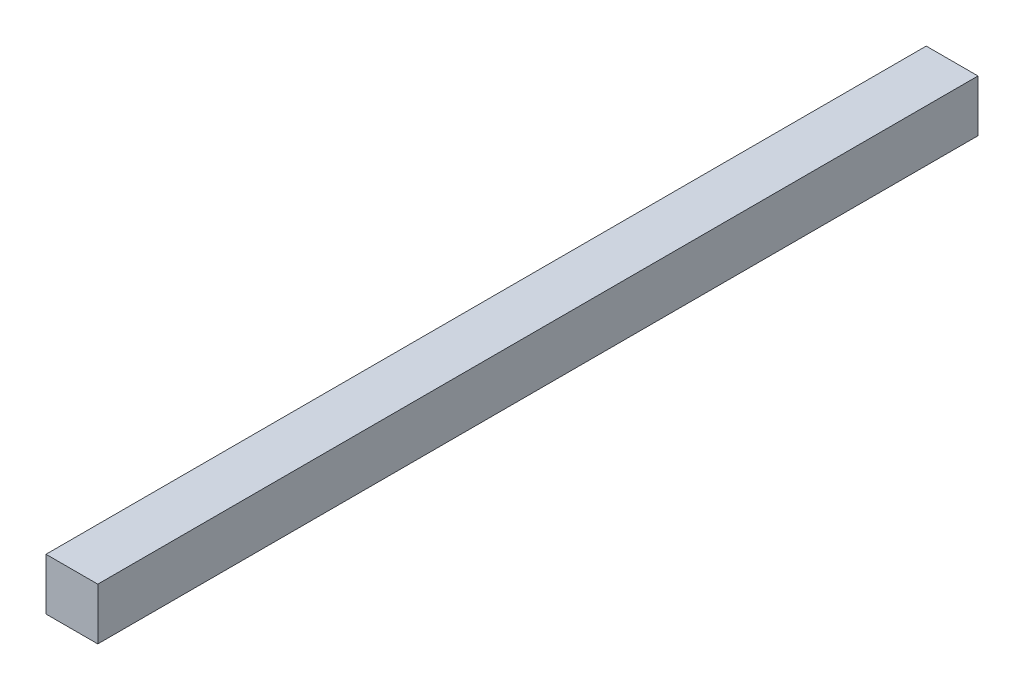
from build123d import *

# Parameters (mm, degrees)
SKETCH1_W           = 25.4
SKETCH1_H           = 25.4
BOSS_EXTRUDE1_DEPTH = 431.8


with BuildPart() as part:
    # Sketch1 → Boss-Extrude1 (new body)
    with BuildSketch(Plane.XY):
        with Locations((12.7, 12.7)):
            Rectangle(SKETCH1_W, SKETCH1_H)
    extrude(amount=BOSS_EXTRUDE1_DEPTH)


solid = part.part
